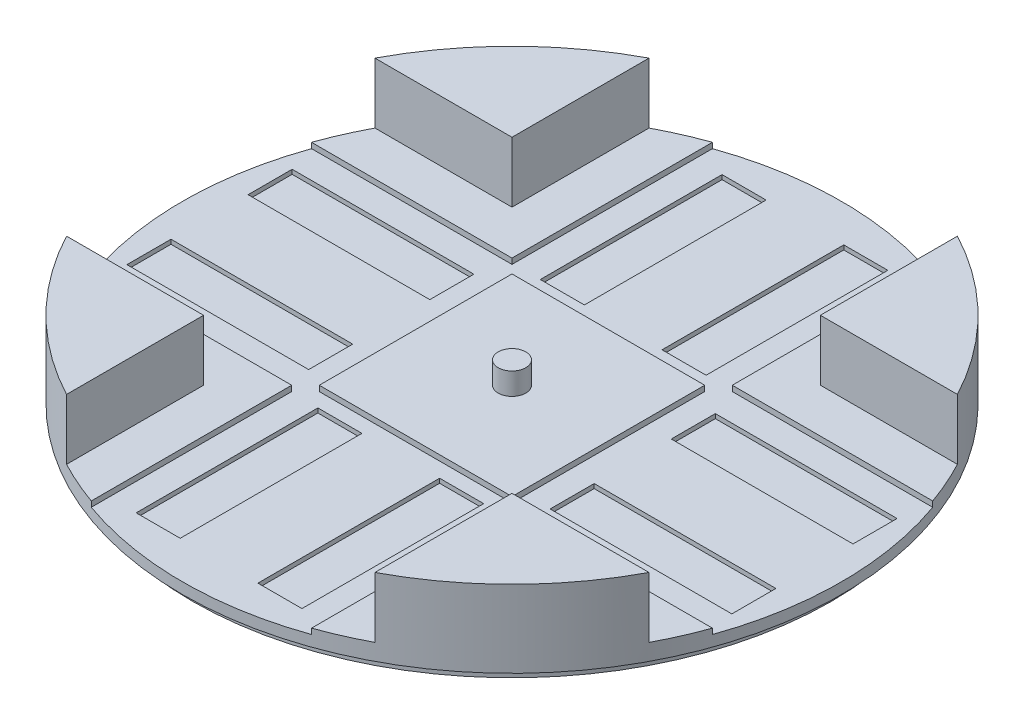
from build123d import *

# Parameters (mm, degrees)
SKETCH2_R           = 76
BOSS_EXTRUDE1_DEPTH = 17.78
CUT_EXTRUDE3_DEPTH  = 13.97
CUT_EXTRUDE4_DEPTH  = 14.97
CUT_EXTRUDE5_DEPTH  = 1.27
SKETCH10_W          = 10.16
SKETCH10_H          = 41.91
SKETCH10_W_2        = 41.91
SKETCH10_H_2        = 10.16
CUT_EXTRUDE6_DEPTH  = 1.016
SKETCH11_W          = 44.45
SKETCH11_H          = 44.45
BOSS_EXTRUDE2_DEPTH = 1.27
SKETCH14_R          = 3.175
BOSS_EXTRUDE4_DEPTH = 5.08
SKETCH15_R          = 73.66
BOSS_EXTRUDE5_DEPTH = 2.54


with BuildPart() as part:
    # Sketch2 → Boss-Extrude1 (new body)
    with BuildSketch(Plane(origin=(0, 0, 0), x_dir=(1, 0, 0), z_dir=(0, 1, 0))):
        Circle(SKETCH2_R)
    extrude(amount=BOSS_EXTRUDE1_DEPTH)

    # Sketch6 → Cut-Extrude3 (cut)
    with BuildSketch(Plane(origin=(0, 17.78, 0), x_dir=(1, 0, 0), z_dir=(0, 1, 0))):
        with BuildLine():
            Line((-76, 35.56), (76, 35.56))
            ThreePointArc((76, 35.56), (111.56, 0), (76, -35.56))
            Line((76, -35.56), (-76, -35.56))
            ThreePointArc((-76, -35.56), (-111.56, 0), (-76, 35.56))
        make_face()
    extrude(amount=-CUT_EXTRUDE3_DEPTH, mode=Mode.SUBTRACT)

    # Sketch8 → Cut-Extrude4 (cut, through all)
    with BuildSketch(Plane(origin=(0, 3.81, 0), x_dir=(1, 0, 0), z_dir=(0, 1, 0))):
        with BuildLine():
            Line((35.56, 76), (35.56, -76))
            ThreePointArc((35.56, -76), (0, -111.56), (-35.56, -76))
            Line((-35.56, -76), (-35.56, 76))
            ThreePointArc((-35.56, 76), (0, 111.56), (35.56, 76))
        make_face()
    extrude(amount=CUT_EXTRUDE4_DEPTH, mode=Mode.SUBTRACT)

    # Sketch9 → Cut-Extrude5 (cut)
    with BuildSketch(Plane(origin=(0, 3.81, 0), x_dir=(1, 0, 0), z_dir=(0, 1, 0))):
        with BuildLine():
            Line((25.4, 76), (25.4, 25.4))
            Line((25.4, 25.4), (76, 25.4))
            ThreePointArc((76, 25.4), (101.4, 0), (76, -25.4))
            Line((76, -25.4), (25.4, -25.4))
            Line((25.4, -25.4), (25.4, -76))
            ThreePointArc((25.4, -76), (0, -101.4), (-25.4, -76))
            Line((-25.4, -76), (-25.4, -25.4))
            Line((-25.4, -25.4), (-76, -25.4))
            ThreePointArc((-76, -25.4), (-101.4, 0), (-76, 25.4))
            Line((-76, 25.4), (-25.4, 25.4))
            Line((-25.4, 25.4), (-25.4, 76))
            ThreePointArc((-25.4, 76), (0, 101.4), (25.4, 76))
        make_face()
    extrude(amount=-CUT_EXTRUDE5_DEPTH, mode=Mode.SUBTRACT)

    # Sketch10 → Cut-Extrude6 (cut)
    with BuildSketch(Plane(origin=(0, 2.54, 0), x_dir=(1, 0, 0), z_dir=(0, 1, 0))):
        with Locations((-14.037724316, 46.60290417)):
            Rectangle(SKETCH10_W, SKETCH10_H)
        with Locations((14.037724316, 46.60290417)):
            Rectangle(SKETCH10_W, SKETCH10_H)
        with Locations((14.037724316, -46.60290417)):
            Rectangle(SKETCH10_W, SKETCH10_H)
        with Locations((-14.037724316, -46.60290417)):
            Rectangle(SKETCH10_W, SKETCH10_H)
        with Locations((-48.79885899, 13.97)):
            Rectangle(SKETCH10_W_2, SKETCH10_H_2)
        with Locations((-48.79885899, -13.97)):
            Rectangle(SKETCH10_W_2, SKETCH10_H_2)
        with Locations((48.79885899, -13.97)):
            Rectangle(SKETCH10_W_2, SKETCH10_H_2)
        with Locations((48.79885899, 13.97)):
            Rectangle(SKETCH10_W_2, SKETCH10_H_2)
    extrude(amount=-CUT_EXTRUDE6_DEPTH, mode=Mode.SUBTRACT)

    # Sketch11 → Boss-Extrude2 (add)
    with BuildSketch(Plane(origin=(0, 2.54, 0), x_dir=(1, 0, 0), z_dir=(0, 1, 0))):
        Rectangle(SKETCH11_W, SKETCH11_H)
    extrude(amount=BOSS_EXTRUDE2_DEPTH)

    # Sketch14 → Boss-Extrude4 (add)
    with BuildSketch(Plane(origin=(0, 3.81, 0), x_dir=(1, 0, 0), z_dir=(0, 1, 0))):
        Circle(SKETCH14_R)
    extrude(amount=BOSS_EXTRUDE4_DEPTH)

    # Sketch15 → Boss-Extrude5 (add)
    with BuildSketch(Plane.XZ):
        Circle(SKETCH15_R)
    extrude(amount=BOSS_EXTRUDE5_DEPTH)


solid = part.part
